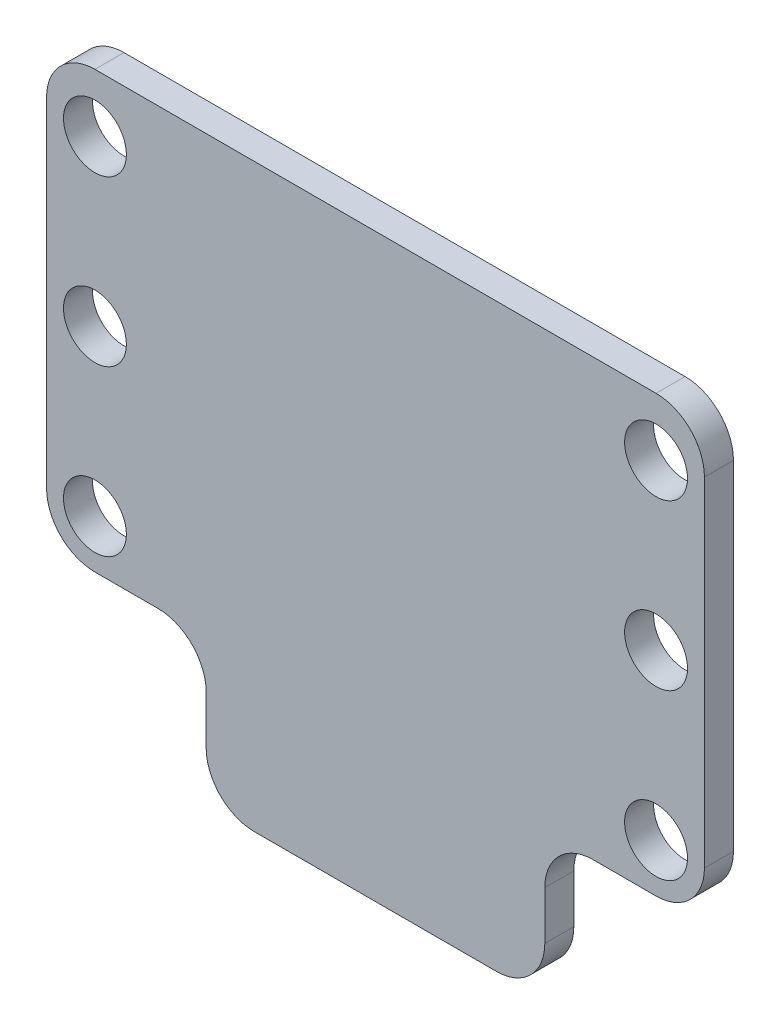
from build123d import *

# Parameters (mm, degrees)
ESQUISSE2_R        = 3.25
BOSS_EXTRU_1_DEPTH = 3
CONG_1_R           = 5


with BuildPart() as part:
    # Esquisse2 → Boss.-Extru.1 (new body)
    with BuildSketch(Plane.XY):
        Polygon((107.208492459, 1.901473412), (39.208492459, 1.901473412), (39.208492459, -43.098526588), (55.708492459, -43.098526588), (55.708492459, -58.098526588), (90.708492459, -58.098526588), (90.708492459, -43.098526588), (107.208492459, -43.098526588), align=None)
        with Locations((102.208492459, -4.098526588)):
            Circle(ESQUISSE2_R, mode=Mode.SUBTRACT)
        with Locations((102.208492459, -38.098526588)):
            Circle(ESQUISSE2_R, mode=Mode.SUBTRACT)
        with Locations((44.208492459, -38.098526588)):
            Circle(ESQUISSE2_R, mode=Mode.SUBTRACT)
        with Locations((44.208492459, -4.098526588)):
            Circle(ESQUISSE2_R, mode=Mode.SUBTRACT)
        with Locations((44.208492459, -21.098526588)):
            Circle(ESQUISSE2_R, mode=Mode.SUBTRACT)
        with Locations((102.208492459, -21.098526588)):
            Circle(ESQUISSE2_R, mode=Mode.SUBTRACT)
    extrude(amount=BOSS_EXTRU_1_DEPTH)

    # Congé1
    cong_1_edges = [part.edges().sort_by_distance(p)[0] for p in [
        (107.208492459, -43.098526588, 1.5),
        (90.708492459, -43.098526588, 1.5),
        (90.708492459, -58.098526588, 1.5),
        (55.708492459, -58.098526588, 1.5),
        (55.708492459, -43.098526588, 1.5),
        (39.208492459, -43.098526588, 1.5),
        (39.208492459, 1.901473412, 1.5),
        (107.208492459, 1.901473412, 1.5),
    ]]
    fillet(cong_1_edges, radius=CONG_1_R)


solid = part.part
